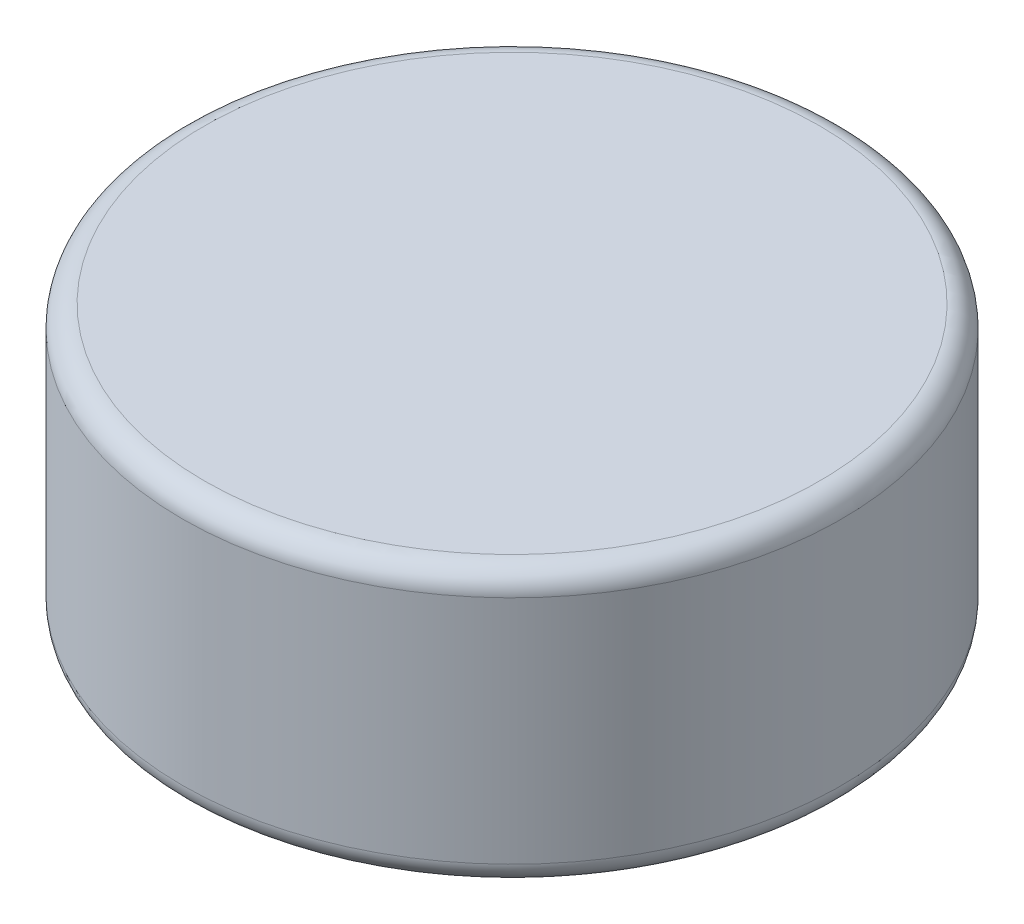
from build123d import *

# Parameters (mm, degrees)
SKETCH1_R           = 3
BOSS_EXTRUDE1_DEPTH = 1.25
FILLET1_R           = 0.2


with BuildPart() as part:
    # Sketch1 → Boss-Extrude1 (new body, symmetric)
    with BuildSketch(Plane(origin=(0, 0, 0), x_dir=(1, 0, 0), z_dir=(0, 1, 0))):
        Circle(SKETCH1_R)
    extrude(amount=BOSS_EXTRUDE1_DEPTH, both=True)

    # Fillet1
    fillet1_edges = [part.edges().sort_by_distance(p)[0] for p in [
        (-3, -1.25, 0),
        (-3, 1.25, 0),
    ]]
    fillet(fillet1_edges, radius=FILLET1_R)


solid = part.part
